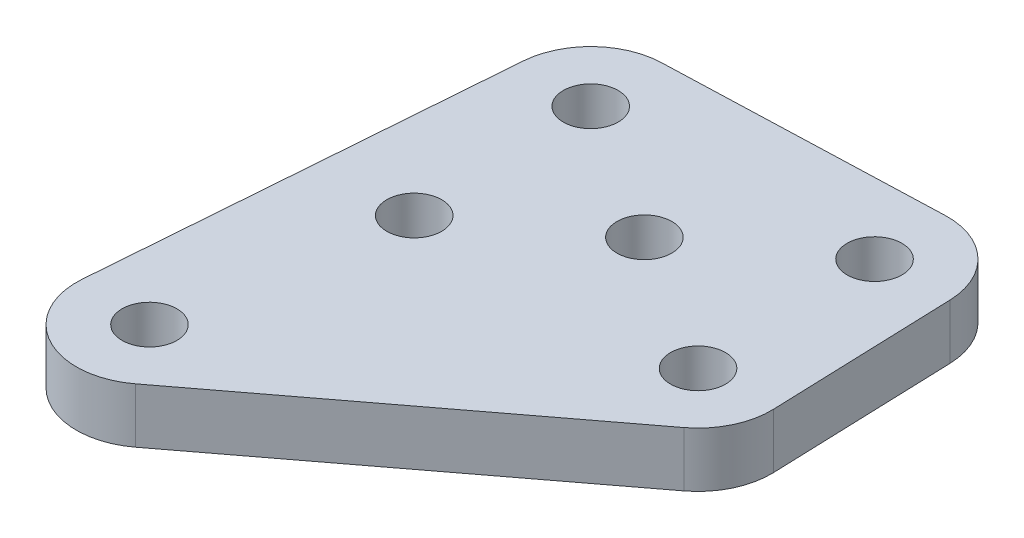
from build123d import *

# Parameters (mm, degrees)
SKETCH1_R           = 1.5
BOSS_EXTRUDE1_DEPTH = 3


with BuildPart() as part:
    # Sketch1 → Boss-Extrude1 (new body)
    with BuildSketch(Plane(origin=(0, 0, 0), x_dir=(1, 0, 0), z_dir=(0, 1, 0))):
        with BuildLine():
            Line((-21.220362367, -4.8401676), (-38.281803408, -17.761164033))
            ThreePointArc((-38.281803408, -17.761164033), (-42.613403289, -18.083291405), (-44.684930136, -14.265530269))
            Line((-44.684930136, -14.265530269), (-42.961821092, 8.128352288))
            ThreePointArc((-42.961821092, 8.128352288), (-41.741950615, 10.708740743), (-39.11256419, 11.819063031))
            Line((-39.11256419, 11.819063031), (-24.121617673, 12.340141252))
            ThreePointArc((-24.121617673, 12.340141252), (-21.254198948, 11.26753095), (-19.985077742, 8.481509707))
            Line((-19.985077742, 8.481509707), (-19.637692261, -1.512454638))
            ThreePointArc((-19.637692261, -1.512454638), (-20.023012527, -3.36941295), (-21.220362367, -4.8401676))
        make_face()
        with Locations((-23.635277999, -1.65140883)):
            Circle(SKETCH1_R, mode=Mode.SUBTRACT)
        with Locations((-31.304443998, 3.085034231)):
            Circle(SKETCH1_R, mode=Mode.SUBTRACT)
        with Locations((-23.98266348, 8.342555514)):
            Circle(SKETCH1_R, mode=Mode.SUBTRACT)
        with Locations((-38.973609998, 7.821477293)):
            Circle(SKETCH1_R, mode=Mode.SUBTRACT)
        with Locations((-38.626224517, -2.172487052)):
            Circle(SKETCH1_R, mode=Mode.SUBTRACT)
        with Locations((-40.696719041, -14.572405264)):
            Circle(SKETCH1_R, mode=Mode.SUBTRACT)
    extrude(amount=BOSS_EXTRUDE1_DEPTH)


solid = part.part
